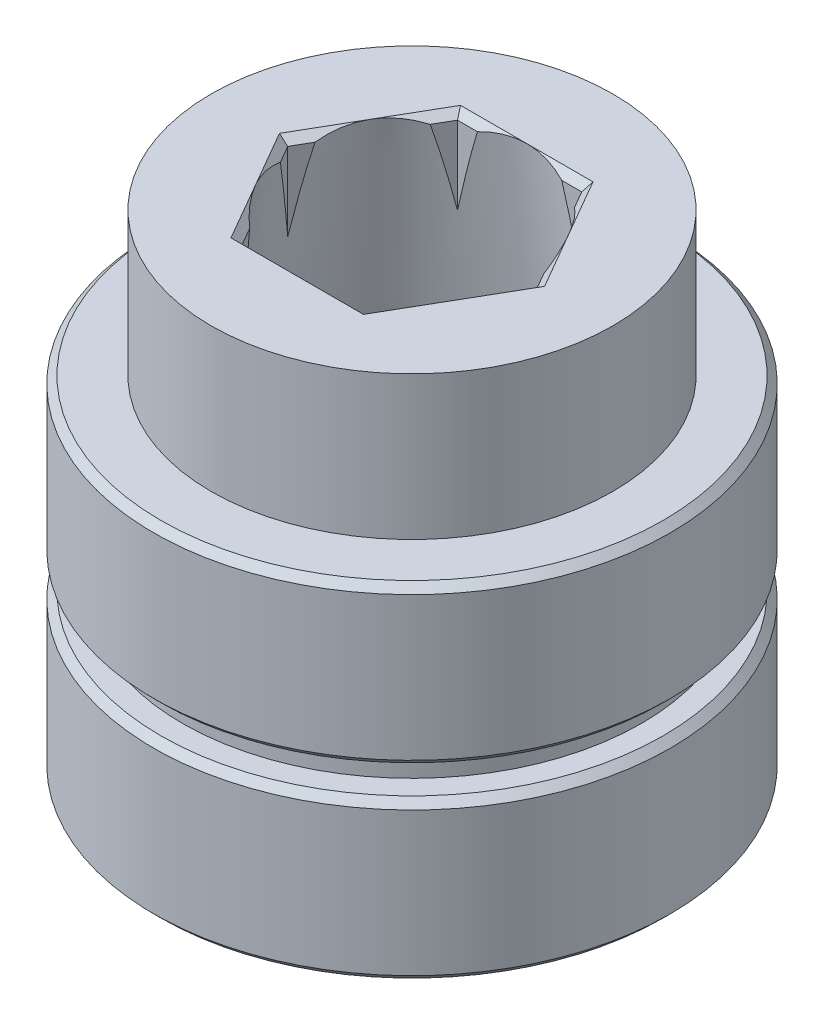
from build123d import *

# Parameters (mm, degrees)
FASE1_SIZE                      = 0.25
SCHNITT_LINEAR_AUSTRAGEN1_DEPTH = 18
FASE2_SIZE                      = 0.25
SKIZZE3_R                       = 7.5
SCHNITT_LINEAR_AUSTRAGEN2_DEPTH = 10
SKIZZE5_R                       = 4
SKIZZE4_R                       = 5.890066201


with BuildPart() as part:
    # Skizze1 → Rotation1 (revolve)
    with BuildSketch(Plane.XY):
        Polygon((0, 0), (9, 0), (9, 5.5), (8, 5.5), (8, 6.5), (9, 6.5), (9, 12), (7, 12), (7, 17), (0, 17), (0, 12), (0, 6.5), (0, 5.5), align=None)
    revolve(axis=Axis((0, -292.433279101, 0), (0, 1, 0)))

    # Fase1
    fase1_edges = [part.edges().sort_by_distance(p)[0] for p in [
        (-9, 6.5, 0),
        (-9, 12, 0),
        (-9, 0, 0),
        (-9, 5.5, 0),
    ]]
    chamfer(fase1_edges, length=FASE1_SIZE)

    # Skizze2 → Schnitt-Linear austragen1 (cut, through all)
    with BuildSketch(Plane(origin=(0, 17, 0), x_dir=(1, 0, 0), z_dir=(0, 1, 0))):
        Polygon((2.165063509, -3.75), (4.330127019, 0), (2.165063509, 3.75), (-2.165063509, 3.75), (-4.330127019, 0), (-2.165063509, -3.75), align=None)
    extrude(amount=-SCHNITT_LINEAR_AUSTRAGEN1_DEPTH, mode=Mode.SUBTRACT)

    # Fase2
    fase2_edges = [part.edges().sort_by_distance(p)[0] for p in [
        (0, 17, 3.75),
        (3.247595264, 17, 1.875),
        (3.247595264, 17, -1.875),
        (0, 17, -3.75),
        (-3.247595264, 17, -1.875),
        (-3.247595264, 17, 1.875),
    ]]
    chamfer(fase2_edges, length=FASE2_SIZE)

    # Skizze3 → Schnitt-Linear austragen2 (cut)
    with BuildSketch(Plane(origin=(0, 0, 0), x_dir=(1, 0, 0), z_dir=(0, 1, 0))):
        with Locations(Location((0, 0, 0), (0, 0, 270))):  # turned: the seam where the file's is
            Circle(SKIZZE3_R)
    extrude(amount=SCHNITT_LINEAR_AUSTRAGEN2_DEPTH, mode=Mode.SUBTRACT)

    # Skizze5 → Schnitt-Ausformung2 section 0
    with BuildSketch(Plane(origin=(0, 17, 0), x_dir=(1, 0, 0), z_dir=(0, 1, 0))):
        Circle(SKIZZE5_R)
    # Skizze4 → Schnitt-Ausformung2 section 1
    with BuildSketch(Plane(origin=(0, 0, 0), x_dir=(1, 0, 0), z_dir=(0, 1, 0))):
        Circle(SKIZZE4_R)
    loft(mode=Mode.SUBTRACT)


solid = part.part
